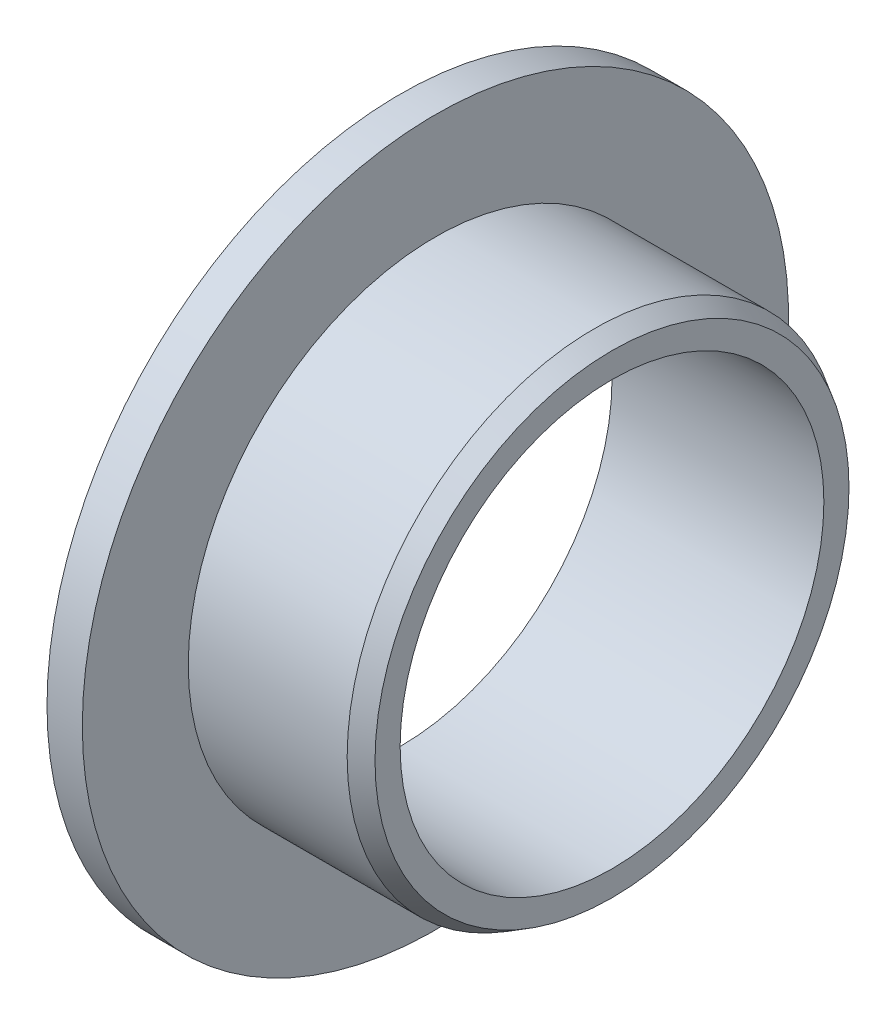
from build123d import *

# Parameters (mm, degrees)
SFAZOWANIE1_SIZE  = 0.5
SFAZOWANIE1_SIZE2 = 0.288675135


with BuildPart() as part:
    # Szkic1 → Obrót1 (revolve)
    with BuildSketch(Plane.XY):
        Polygon((0, 6), (6, 6), (6, 7), (1, 7), (1, 10), (0, 10), align=None)
    revolve(axis=Axis((0, 0, 0), (1, 0, 0)))

    # Sfazowanie1
    sfazowanie1_edges = [part.edges().sort_by_distance(p)[0] for p in [
        (6, -7, 0),
    ]]
    sfazowanie1_side = [part.faces().sort_by_distance(p)[0] for p in [
        (3.5, -7, 0),
    ]]
    chamfer(sfazowanie1_edges, length=SFAZOWANIE1_SIZE, length2=SFAZOWANIE1_SIZE2, reference=sfazowanie1_side[0])


solid = part.part
